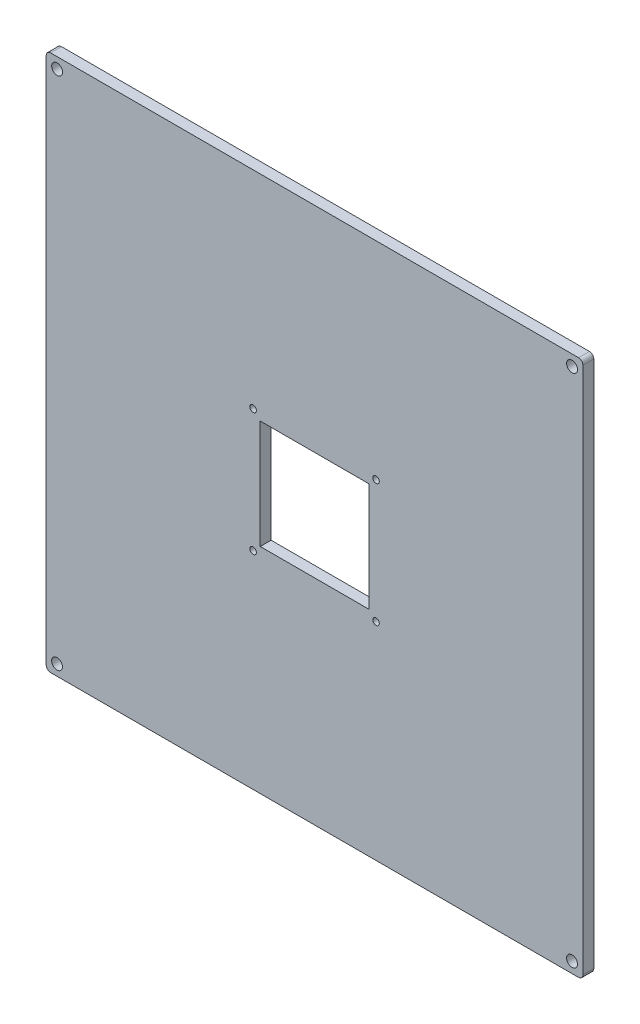
from build123d import *

# Parameters (mm, degrees)
SKETCH1_R           = 2.5
BOSS_EXTRUDE1_DEPTH = 5
SKETCH2_R           = 1.5
SKETCH2_W           = 50
SKETCH2_H           = 50
CUT_EXTRUDE1_DEPTH  = 5


with BuildPart() as part:
    # Sketch1 → Boss-Extrude1 (new body)
    with BuildSketch(Plane.XY):
        with BuildLine():
            Line((-123.5, 121.5), (-123.5, -121.5))
            ThreePointArc((-123.5, -121.5), (-122.914213562, -122.914213562), (-121.5, -123.5))
            Line((-121.5, -123.5), (121.5, -123.5))
            ThreePointArc((121.5, -123.5), (122.914213562, -122.914213562), (123.5, -121.5))
            Line((123.5, -121.5), (123.5, 121.5))
            ThreePointArc((123.5, 121.5), (122.914213562, 122.914213562), (121.5, 123.5))
            Line((121.5, 123.5), (-121.5, 123.5))
            ThreePointArc((-121.5, 123.5), (-122.914213562, 122.914213562), (-123.5, 121.5))
        make_face()
        with Locations((-118.5, 118.5)):
            Circle(SKETCH1_R, mode=Mode.SUBTRACT)
        with Locations((118.5, 118.5)):
            Circle(SKETCH1_R, mode=Mode.SUBTRACT)
        with Locations((118.5, -118.5)):
            Circle(SKETCH1_R, mode=Mode.SUBTRACT)
        with Locations((-118.5, -118.5)):
            Circle(SKETCH1_R, mode=Mode.SUBTRACT)
    extrude(amount=BOSS_EXTRUDE1_DEPTH)

    # Sketch2 → Cut-Extrude1 (cut)
    with BuildSketch(Plane(origin=(0, 0, 0), x_dir=(-1, 0, 0), z_dir=(0, 0, -1))):
        with Locations((28.284271247, 28.284271247)):
            Circle(SKETCH2_R)
        with Locations((28.284271247, -28.284271247)):
            Circle(SKETCH2_R)
        with Locations((-28.284271247, -28.284271247)):
            Circle(SKETCH2_R)
        with Locations((-28.284271247, 28.284271247)):
            Circle(SKETCH2_R)
        Rectangle(SKETCH2_W, SKETCH2_H)
    extrude(amount=-CUT_EXTRUDE1_DEPTH, mode=Mode.SUBTRACT)


solid = part.part
